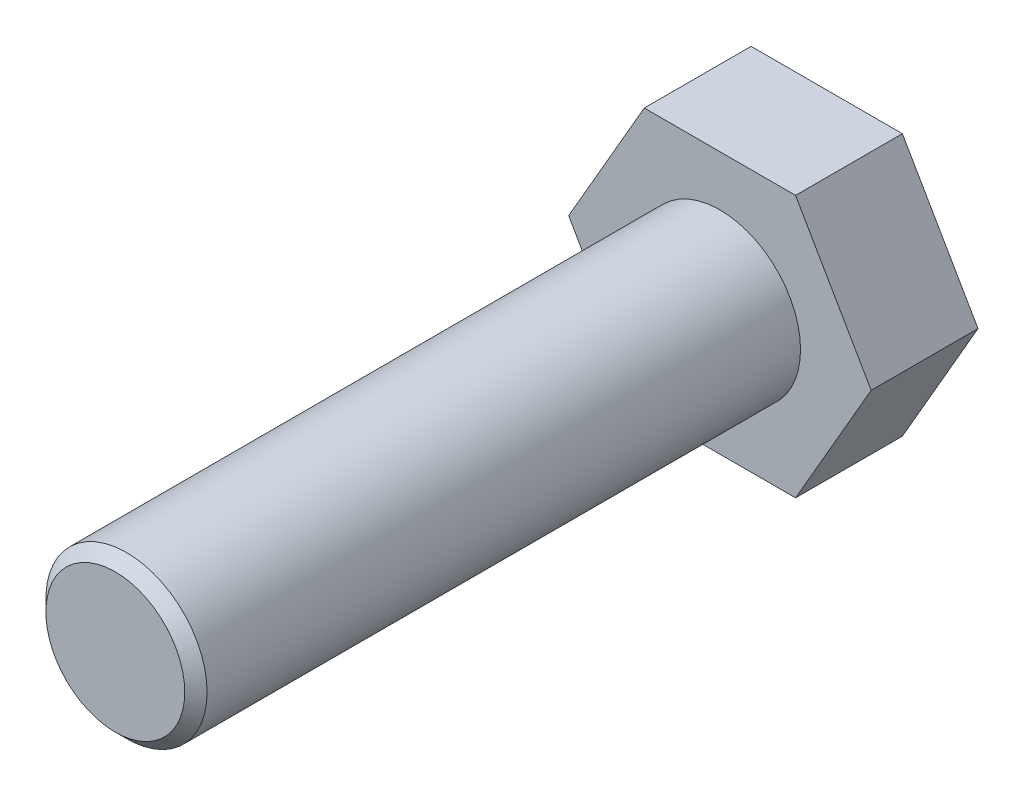
from build123d import *

# Parameters (mm, degrees)
EXTRUDE_1_DEPTH = 5.3
SKETCH_2_R      = 4
EXTRUDE_2_DEPTH = 30
CHAMFER_1_SIZE  = 0.5545


with BuildPart() as part:
    # Эскиз1 → Бобышка-Вытянуть1 (new body)
    with BuildSketch(Plane.XY):
        Polygon((3.75277675, 6.5), (-3.75277675, 6.5), (-7.505553499, 0), (-3.75277675, -6.5), (3.75277675, -6.5), (7.505553499, 0), align=None)
    extrude(amount=EXTRUDE_1_DEPTH)

    # Эскиз2 → Бобышка-Вытянуть2 (add)
    with BuildSketch(Plane.XY.offset(5.3)):
        Circle(SKETCH_2_R)
    extrude(amount=EXTRUDE_2_DEPTH)

    # Фаска1
    chamfer_1_edges = [part.edges().sort_by_distance(p)[0] for p in [
        (-4, 0, 35.3),
    ]]
    chamfer(chamfer_1_edges, length=CHAMFER_1_SIZE)


solid = part.part
